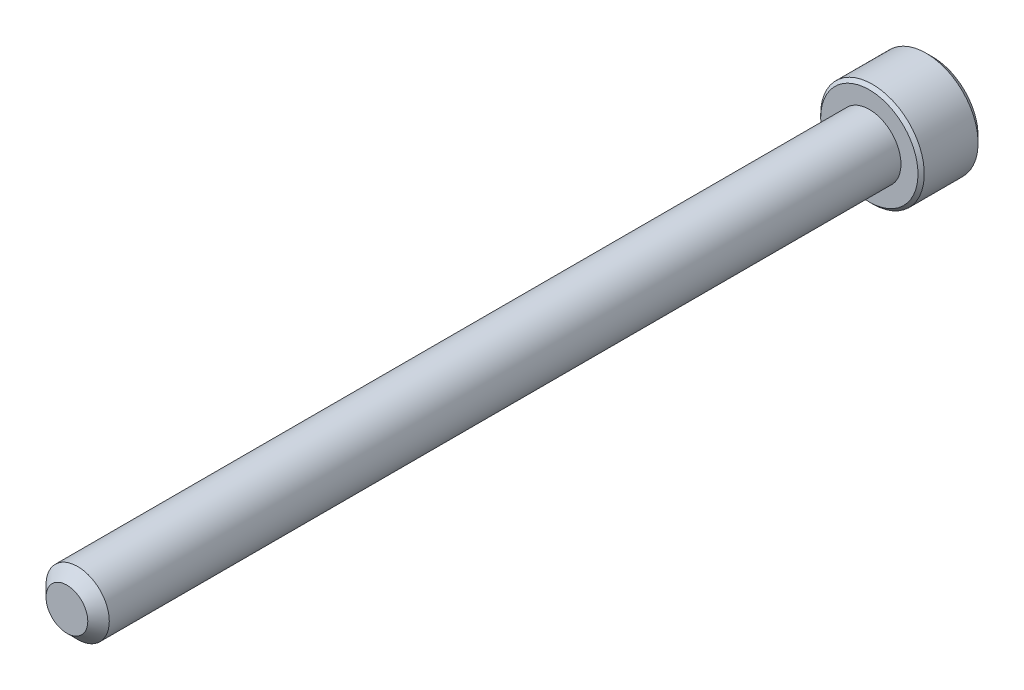
from build123d import *

# Parameters (mm, degrees)
SKETCH1_R          = 1.7526
EXTRUDE1_DEPTH     = 44.45
CHAMFER3_SIZE      = 0.5953125
SKETCH6_R          = 2.8702
EXTRUDE2_DEPTH     = 3.5052
CUT_EXTRUDE1_DEPTH = 2.08359375
SKETCH8_R          = 1.603951217
CUT_EXTRUDE2_DEPTH = 0.35052
CUT_EXTRUDE2_DRAFT = -45
CHAMFER1_SIZE      = 0.35052
CHAMFER2_SIZE      = 0.17526


with BuildPart() as part:
    # Sketch1 → Extrude1 (new body)
    with BuildSketch(Plane.XY):
        Circle(SKETCH1_R)
    extrude(amount=-EXTRUDE1_DEPTH)

    # Chamfer3
    chamfer3_edges = [part.edges().sort_by_distance(p)[0] for p in [
        (-1.7526, 0, 0),
    ]]
    chamfer(chamfer3_edges, length=CHAMFER3_SIZE)

    # Sketch5 → partially thread (revolve)
    with BuildSketch(Plane(origin=(0, 0, 0), x_dir=(0, 0, -1), z_dir=(1, 0, 0))):
        Polygon((44.45, 1.7526), (19.05, 1.7526), (17.2974, 0), (19.05, 0), (44.45, 0), align=None)
    revolve(axis=Axis((0, 0, 0), (0, 0, -1)))

    # Sketch6 → Extrude2 (add)
    with BuildSketch(Plane(origin=(0, 0, -44.45), x_dir=(-1, 0, 0), z_dir=(0, 0, -1))):
        Circle(SKETCH6_R)
    extrude(amount=EXTRUDE2_DEPTH)

    # Sketch7 → Cut-Extrude1 (cut)
    with BuildSketch(Plane(origin=(0, 0, -47.9552), x_dir=(-1, 0, 0), z_dir=(0, 0, -1))):
        Polygon((0, 1.603951217), (-1.3890625, 0.801975608), (-1.3890625, -0.801975608), (0, -1.603951217), (1.3890625, -0.801975608), (1.3890625, 0.801975608), align=None)
    extrude(amount=-CUT_EXTRUDE1_DEPTH, mode=Mode.SUBTRACT)


with BuildPart() as cut_extrude2_tool:
    # Sketch8 → Cut-Extrude2 (with draft: the straight prism first)
    with BuildSketch(Plane(origin=(0, 0, -47.9552), x_dir=(-1, 0, 0), z_dir=(0, 0, -1))):
        Circle(SKETCH8_R)
    extrude(amount=-CUT_EXTRUDE2_DEPTH)
    # Cut-Extrude2: the draft: its side faces are tilted about the plane it starts from
    cut_extrude2_sides = [cut_extrude2_tool.faces().sort_by_distance(p)[0] for p in [
        (1.603951217, 0, -47.77994),
    ]]
    draft(cut_extrude2_sides, Plane(origin=(0, 0, -47.9552), x_dir=(-1, 0, 0), z_dir=(0, 0, -1)), CUT_EXTRUDE2_DRAFT)


with BuildPart() as part_1:
    add(part.part)

    # Cut-Extrude2: cut by cut_extrude2_tool
    add(cut_extrude2_tool.part, mode=Mode.SUBTRACT)

    # Chamfer1
    chamfer1_edges = [part_1.edges().sort_by_distance(p)[0] for p in [
        (2.8702, 0, -47.9552),
    ]]
    chamfer(chamfer1_edges, length=CHAMFER1_SIZE)

    # Chamfer2
    chamfer2_edges = [part_1.edges().sort_by_distance(p)[0] for p in [
        (2.8702, 0, -44.45),
    ]]
    chamfer(chamfer2_edges, length=CHAMFER2_SIZE)


solid = part_1.part
